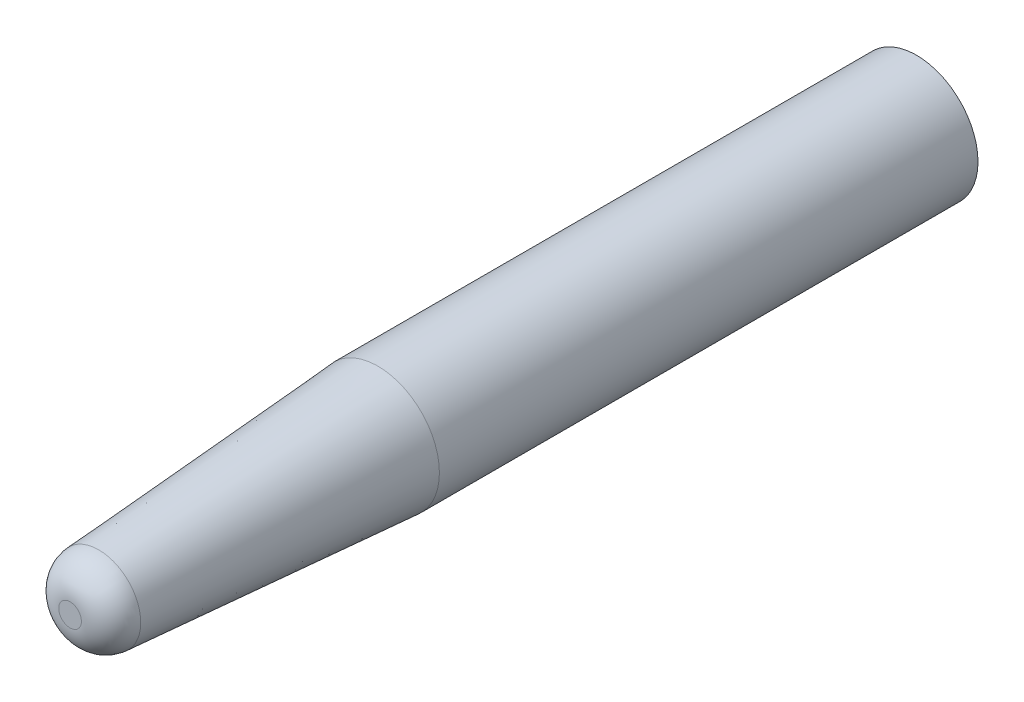
from build123d import *

# Parameters (mm, degrees)
SKETCH1_R           = 2
BOSS_EXTRUDE1_DEPTH = 10
BOSS_EXTRUDE1_TAPER = 4
SKETCH1_2_R         = 2
BOSS_EXTRUDE2_DEPTH = 17.5
FILLET1_R           = 1


with BuildPart() as part:
    # Sketch1 → Boss-Extrude1 (new body)
    with BuildSketch(Plane.XY):
        Circle(SKETCH1_R)
    extrude(amount=BOSS_EXTRUDE1_DEPTH, taper=BOSS_EXTRUDE1_TAPER)

    # Sketch1_2 → Boss-Extrude2 (add)
    with BuildSketch(Plane.XY):
        Circle(SKETCH1_2_R)
    extrude(amount=-BOSS_EXTRUDE2_DEPTH)

    # Fillet1
    fillet1_edges = [part.edges().sort_by_distance(p)[0] for p in [
        (-1.300731881, 0, 10),
    ]]
    fillet(fillet1_edges, radius=FILLET1_R)


solid = part.part
